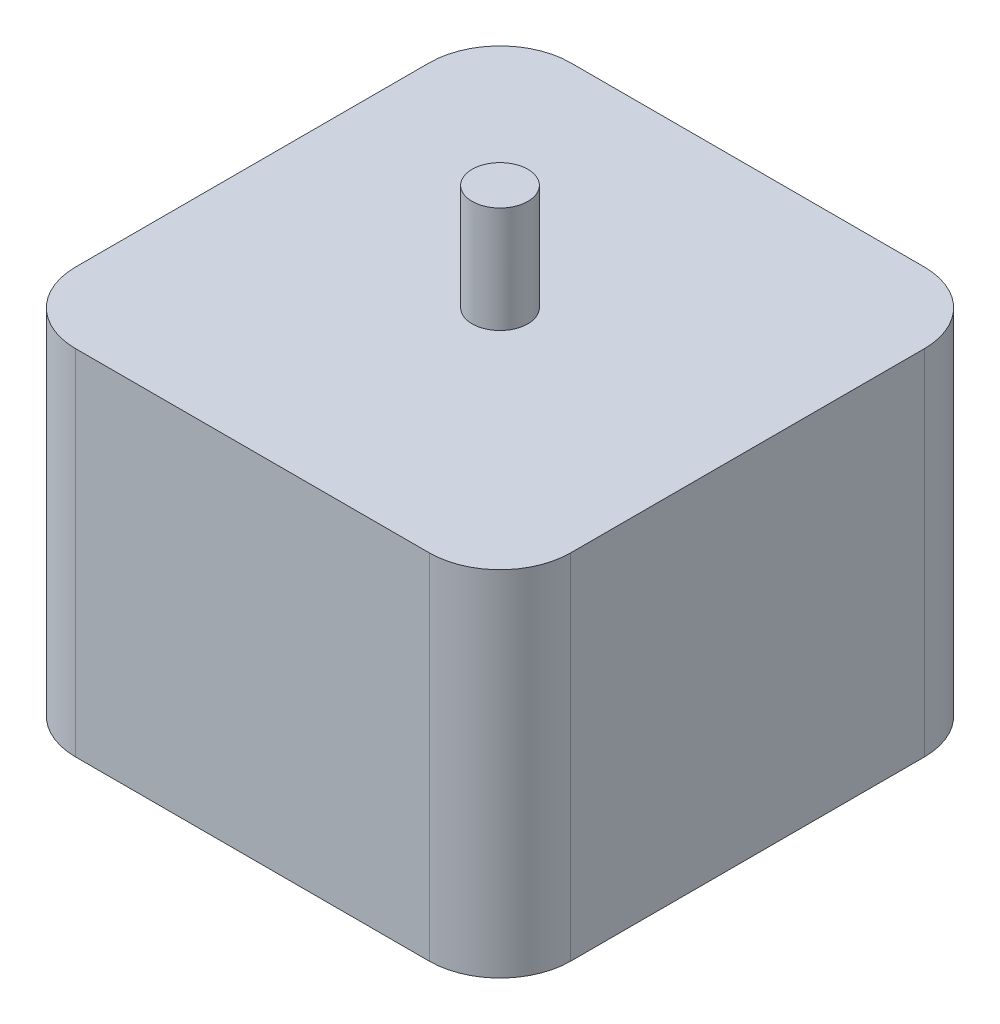
from build123d import *

# Parameters (mm, degrees)
SKETCH1_W           = 44.45
SKETCH1_H           = 44.45
BOSS_EXTRUDE1_DEPTH = 31.75
FILLET1_R           = 6.35
SKETCH2_R           = 2.5
BOSS_EXTRUDE2_DEPTH = 9.525
SKETCH4_R           = 2.5
BOSS_EXTRUDE3_DEPTH = 9.525


with BuildPart() as part:
    # Sketch1 → Boss-Extrude1 (new body)
    with BuildSketch(Plane(origin=(0, 0, 0), x_dir=(1, 0, 0), z_dir=(0, 1, 0))):
        Rectangle(SKETCH1_W, SKETCH1_H)
    extrude(amount=BOSS_EXTRUDE1_DEPTH)

    # Fillet1
    fillet1_edges = [part.edges().sort_by_distance(p)[0] for p in [
        (22.225, 15.875, 22.225),
        (-22.225, 15.875, 22.225),
        (-22.225, 15.875, -22.225),
        (22.225, 15.875, -22.225),
    ]]
    fillet(fillet1_edges, radius=FILLET1_R)

    # Sketch2 → Boss-Extrude2 (add)
    with BuildSketch(Plane(origin=(0, 31.75, 0), x_dir=(1, 0, 0), z_dir=(0, 1, 0))):
        Circle(SKETCH2_R)
    extrude(amount=BOSS_EXTRUDE2_DEPTH)

    # Sketch4 → Boss-Extrude3 (add)
    with BuildSketch(Plane.XZ):
        Circle(SKETCH4_R)
    extrude(amount=BOSS_EXTRUDE3_DEPTH)


solid = part.part
